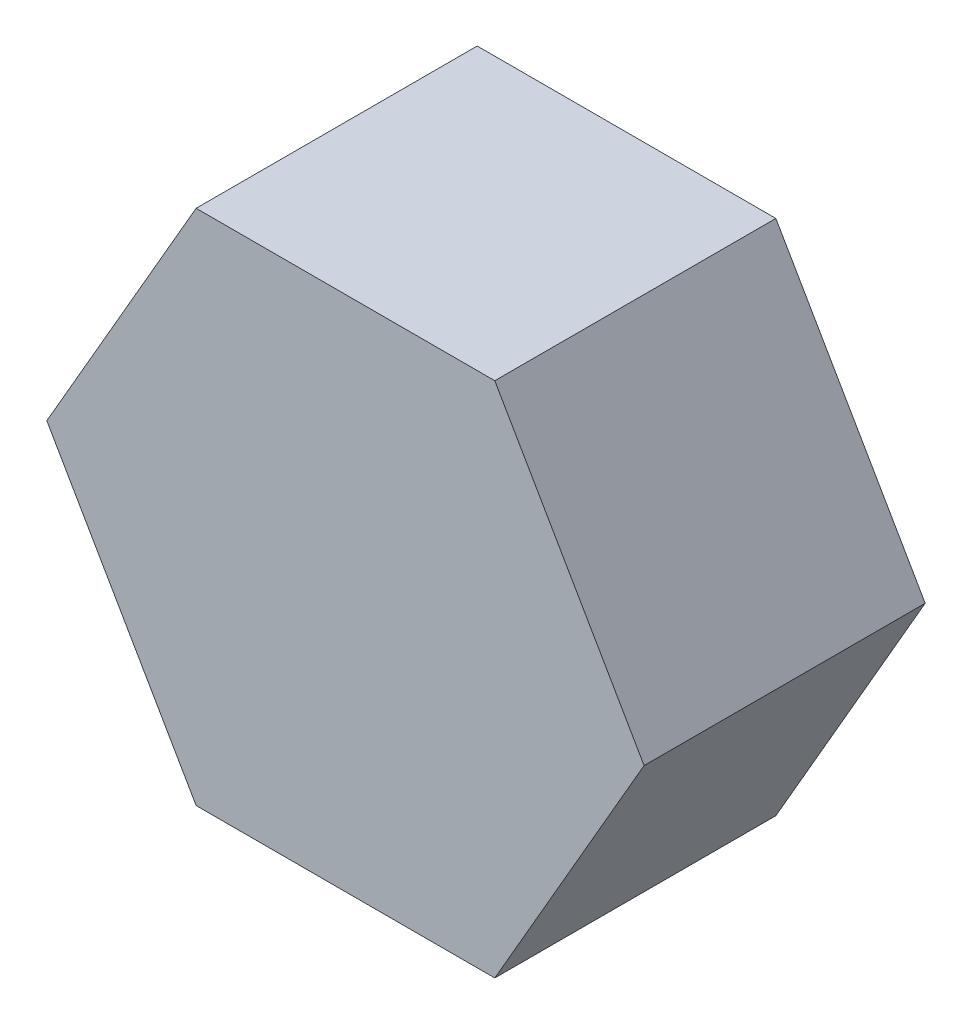
from build123d import *

# Parameters (mm, degrees)
BOSS_EXTRUDE1_DEPTH = 8


with BuildPart() as part:
    # Sketch1 → Boss-Extrude1 (new body)
    with BuildSketch(Plane.XY):
        Polygon((-20.867086356, 25.218992545), (-12.367086356, 25.218992545), (-8.117086356, 17.857776613), (-12.367086356, 10.496560681), (-20.867086356, 10.496560681), (-25.117086356, 17.857776613), align=None)
    extrude(amount=BOSS_EXTRUDE1_DEPTH)


solid = part.part
